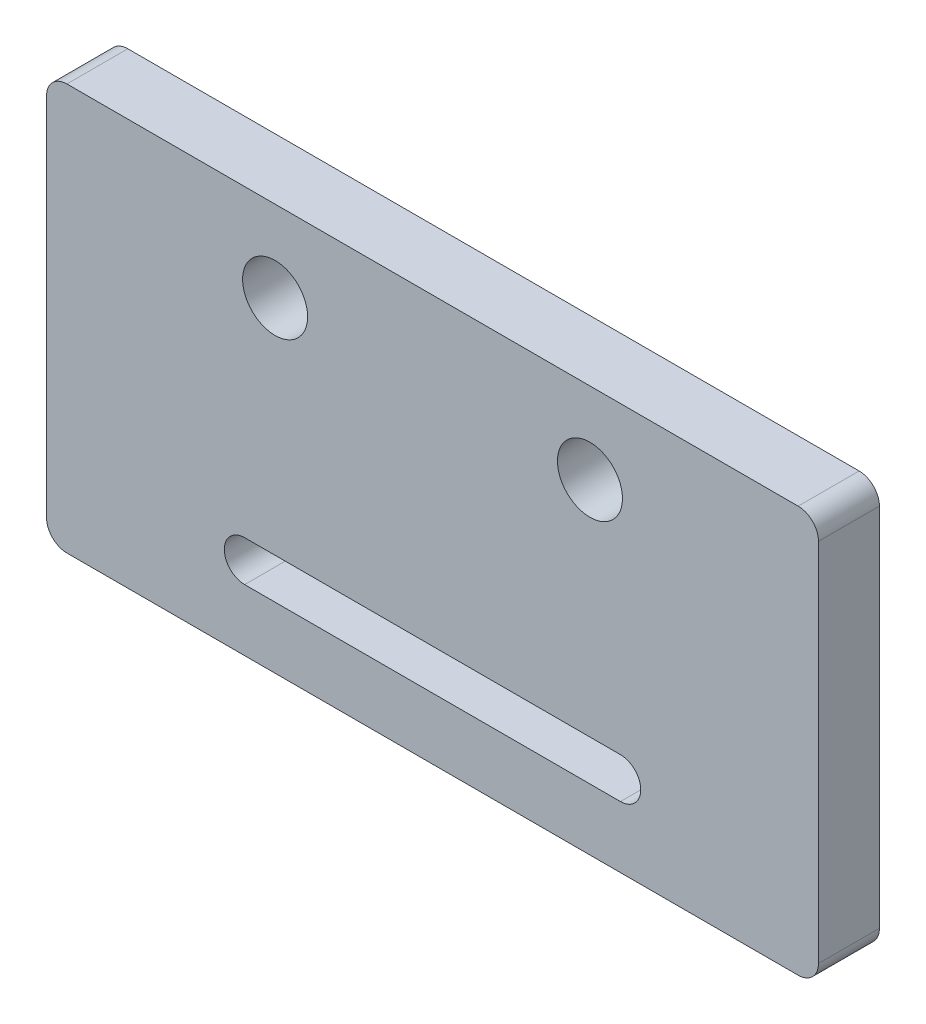
from build123d import *

# Parameters (mm, degrees)
SKETCH1_W                = 38
SKETCH1_H                = 20
BOSS_EXTRUDE1_DEPTH      = 3
M3_CLEARANCE_HOLE1_D     = 3.2
M3_CLEARANCE_HOLE1_DEPTH = 20
M3_CLEARANCE_HOLE1_TIP   = 0.96137699
CUT_EXTRUDE1_DEPTH       = 3
FILLET1_R                = 1


with BuildPart() as part:
    # Sketch1 → Boss-Extrude1 (new body)
    with BuildSketch(Plane.XY):
        with Locations((-19, 10)):
            Rectangle(SKETCH1_W, SKETCH1_H)
    extrude(amount=BOSS_EXTRUDE1_DEPTH)

    # M3 Clearance Hole1
    with Locations(Plane.XY.offset(3)):
        with Locations((-11.25, 16), (-26.75, 16)):
            Hole(M3_CLEARANCE_HOLE1_D / 2, depth=M3_CLEARANCE_HOLE1_DEPTH)
            with Locations((0, 0, -(M3_CLEARANCE_HOLE1_DEPTH + M3_CLEARANCE_HOLE1_TIP / 2))):  # 118° drill point
                Cone(0, M3_CLEARANCE_HOLE1_D / 2, M3_CLEARANCE_HOLE1_TIP, mode=Mode.SUBTRACT)

    # Sketch4 → Cut-Extrude1 (cut)
    with BuildSketch(Plane.XY.offset(3)):
        with BuildLine():
            Line((-9.75, 5.03), (-28.25, 5.03))
            ThreePointArc((-28.25, 5.03), (-29.25, 4.03), (-28.25, 3.03))
            Line((-28.25, 3.03), (-9.75, 3.03))
            ThreePointArc((-9.75, 3.03), (-8.75, 4.03), (-9.75, 5.03))
        make_face()
    extrude(amount=-CUT_EXTRUDE1_DEPTH, mode=Mode.SUBTRACT)

    # Fillet1
    fillet1_edges = [part.edges().sort_by_distance(p)[0] for p in [
        (0, 0, 1.5),
        (-38, 0, 1.5),
        (-38, 20, 1.5),
        (0, 20, 1.5),
    ]]
    fillet(fillet1_edges, radius=FILLET1_R)


solid = part.part
